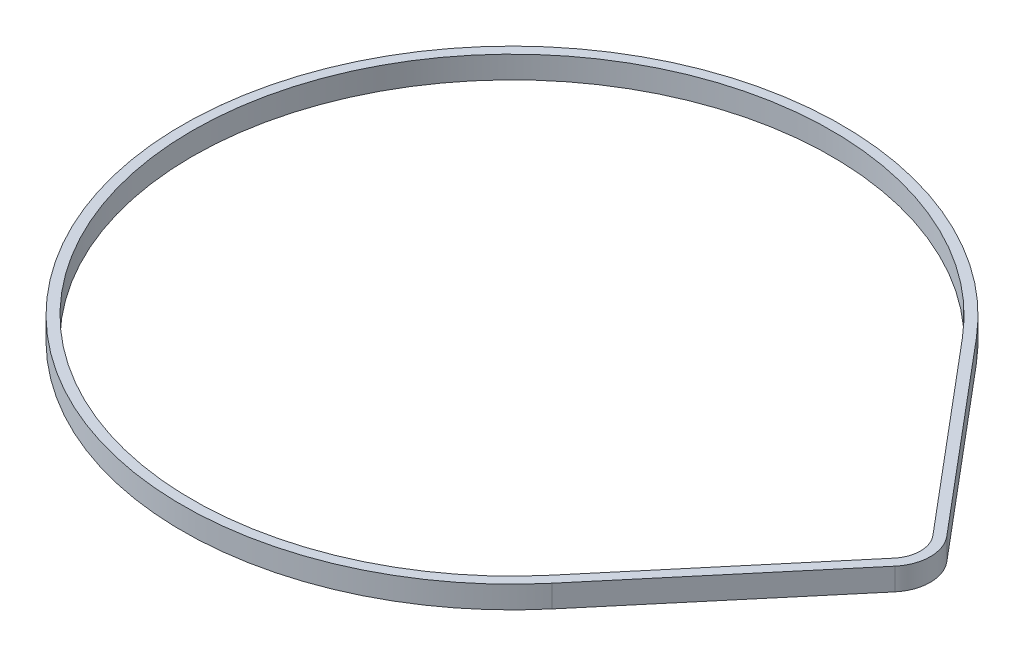
from build123d import *

# Parameters (mm, degrees)
EXTRUDE1_DEPTH = 3.0988


with BuildPart() as part:
    # Sketch1 → Extrude1 (new body)
    with BuildSketch(Plane(origin=(0, 0, 0), x_dir=(1, 0, 0), z_dir=(0, 1, 0))):
        with BuildLine():
            Line((35.063485217, 29.498661511), (56.854034783, 3.597397745))
            ThreePointArc((56.854034783, 3.597397745), (58.166, 0), (56.854034783, -3.597397745))
            Line((56.854034783, -3.597397745), (35.063485217, -29.498661511))
            ThreePointArc((35.063485217, -29.498661511), (-45.8216, 0), (35.063485217, 29.498661511))
        make_face()
        with BuildLine():
            Line((55.804462609, -2.714400117), (34.013913043, -28.615663883))
            ThreePointArc((34.013913043, -28.615663883), (-44.45, 0), (34.013913043, 28.615663883))
            Line((34.013913043, 28.615663883), (55.804462609, 2.714400117))
            ThreePointArc((55.804462609, 2.714400117), (56.7944, 0), (55.804462609, -2.714400117))
        make_face(mode=Mode.SUBTRACT)
    extrude(amount=EXTRUDE1_DEPTH)


solid = part.part
